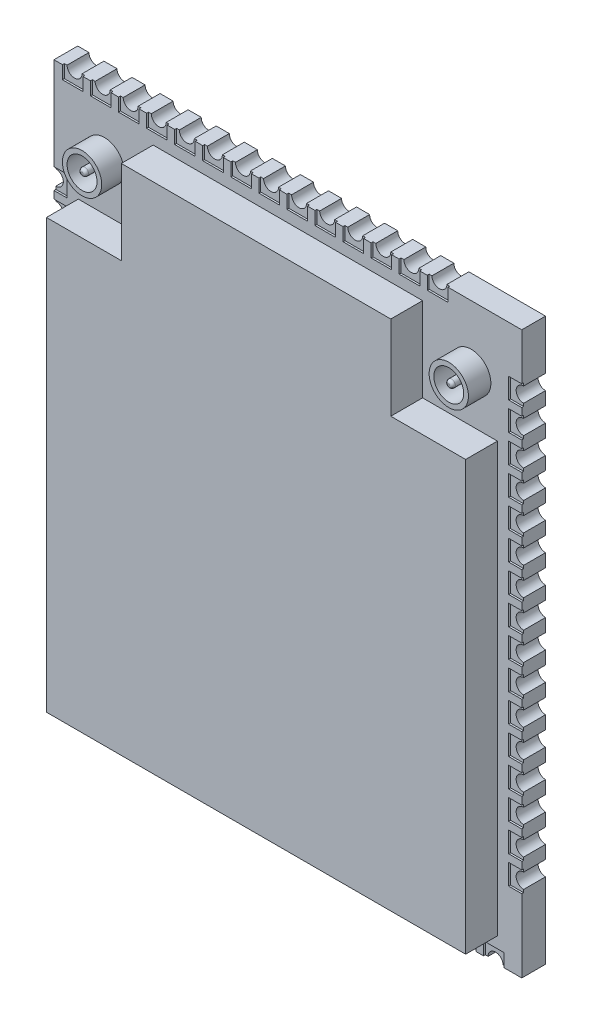
from build123d import *

# Parameters (mm, degrees)
SKETCH1_W            = 25
SKETCH1_H            = 30
BOSS_EXTRUDE1_DEPTH  = 1.27
BOSS_EXTRUDE2_DEPTH  = 1.7
SKETCH3_R            = 1.05
SKETCH3_R_2          = 0.8
SKETCH3_R_3          = 0.2
BOSS_EXTRUDE3_DEPTH  = 1.2
FILLET1_R            = 0.15
FILLET1_OF_MIRROR1_R = 0.15
CUT_EXTRUDE1_DEPTH   = 1.27
SKETCH5_W            = 0.7
SKETCH5_H            = 1.1
CUT_EXTRUDE2_DEPTH   = 0.1
LPATTERN1_COUNT      = 14
LPATTERN1_PITCH      = 1.5
CUT_EXTRUDE3_DEPTH   = 1.27
SKETCH7_W            = 1.1
SKETCH7_H            = 0.7
CUT_EXTRUDE4_DEPTH   = 0.1
CUT_EXTRUDE5_DEPTH   = 1.27
SKETCH10_W           = 0.7
SKETCH10_H           = 1.1
CUT_EXTRUDE6_DEPTH   = 0.1
CUT_EXTRUDE7_DEPTH   = 1.27
SKETCH12_W           = 1.1
SKETCH12_H           = 0.7
CUT_EXTRUDE8_DEPTH   = 0.1
LPATTERN2_COUNT      = 16
LPATTERN2_PITCH      = 1.5
LPATTERN3_COUNT      = 16
LPATTERN3_PITCH      = 1.5
LPATTERN4_COUNT      = 14
LPATTERN4_PITCH      = 1.5


with BuildPart() as part:
    # Sketch1 → Boss-Extrude1 (new body)
    with BuildSketch(Plane.XY):
        with Locations((12.5, 15)):
            Rectangle(SKETCH1_W, SKETCH1_H)
    extrude(amount=BOSS_EXTRUDE1_DEPTH)

    # Sketch2 → Boss-Extrude2 (add)
    with BuildSketch(Plane.XY.offset(1.27)):
        Polygon((5.3, 28.7), (19.7, 28.7), (19.7, 24.2), (23.7, 24.2), (23.7, 1.3), (1.3, 1.3), (1.3, 24.2), (5.3, 24.2), align=None)
    extrude(amount=BOSS_EXTRUDE2_DEPTH)

    # Sketch3 → Boss-Extrude3 (add)
    with BuildSketch(Plane.XY.offset(1.27)):
        with Locations((22.3, 26.7)):
            Circle(SKETCH3_R)
        with Locations((22.3, 26.7)):
            Circle(SKETCH3_R_2, mode=Mode.SUBTRACT)
        with Locations((22.3, 26.7)):
            Circle(SKETCH3_R_3)
    boss_extrude3 = extrude(amount=BOSS_EXTRUDE3_DEPTH)

    # Fillet1
    fillet1_edges = [part.edges().sort_by_distance(p)[0] for p in [
        (22.1, 26.7, 2.47),
    ]]
    fillet(fillet1_edges, radius=FILLET1_R)

    # Mirror1: Boss-Extrude3 across plane
    add(boss_extrude3.mirror(Plane(origin=(12.5, 0, 0), x_dir=(0, 0, 1), z_dir=(1, 0, 0))))

    # Fillet1 of Mirror1
    fillet1_of_mirror1_edges = [part.edges().sort_by_distance(p)[0] for p in [
        (2.9, 26.7, 2.47),
    ]]
    fillet(fillet1_of_mirror1_edges, radius=FILLET1_OF_MIRROR1_R)

    # Sketch4 → Cut-Extrude1 (cut)
    with BuildSketch(Plane.XY.offset(1.27)):
        with BuildLine():
            Line((0, 5.4), (0, 4.6))
            ThreePointArc((0, 4.6), (0.4, 5), (0, 5.4))
        make_face()
    cut_extrude1 = extrude(amount=-CUT_EXTRUDE1_DEPTH, mode=Mode.SUBTRACT)

    # Sketch5 → Cut-Extrude2 (cut)
    with BuildSketch(Plane.XY.offset(1.27)):
        with Locations((0.35, 5)):
            Rectangle(SKETCH5_W, SKETCH5_H)
    cut_extrude2 = extrude(amount=-CUT_EXTRUDE2_DEPTH, mode=Mode.SUBTRACT)

    # LPattern1: Cut-Extrude1, Cut-Extrude2 ×14
    with Locations(*[(0, i * LPATTERN1_PITCH, 0) for i in range(1, LPATTERN1_COUNT)]):
        add(cut_extrude1, mode=Mode.SUBTRACT)
        add(cut_extrude2, mode=Mode.SUBTRACT)

    # Sketch6 → Cut-Extrude3 (cut)
    with BuildSketch(Plane.XY.offset(1.27)):
        with BuildLine():
            Line((0.6, 0), (1.4, 0))
            ThreePointArc((1.4, 0), (1, 0.4), (0.6, 0))
        make_face()
    cut_extrude3 = extrude(amount=-CUT_EXTRUDE3_DEPTH, mode=Mode.SUBTRACT)

    # Sketch7 → Cut-Extrude4 (cut)
    with BuildSketch(Plane.XY.offset(1.27)):
        with Locations((1, 0.35)):
            Rectangle(SKETCH7_W, SKETCH7_H)
    cut_extrude4 = extrude(amount=-CUT_EXTRUDE4_DEPTH, mode=Mode.SUBTRACT)

    # Sketch9 → Cut-Extrude5 (cut)
    with BuildSketch(Plane.XY.offset(1.27)):
        with BuildLine():
            Line((25, 4.85), (25, 4.05))
            ThreePointArc((25, 4.05), (24.6, 4.45), (25, 4.85))
        make_face()
    cut_extrude5 = extrude(amount=-CUT_EXTRUDE5_DEPTH, mode=Mode.SUBTRACT)

    # Sketch10 → Cut-Extrude6 (cut)
    with BuildSketch(Plane.XY.offset(1.27)):
        with Locations((24.65, 4.45)):
            Rectangle(SKETCH10_W, SKETCH10_H)
    cut_extrude6 = extrude(amount=-CUT_EXTRUDE6_DEPTH, mode=Mode.SUBTRACT)

    # Sketch11 → Cut-Extrude7 (cut)
    with BuildSketch(Plane.XY.offset(1.27)):
        with BuildLine():
            Line((0.6, 30), (1.4, 30))
            ThreePointArc((1.4, 30), (1, 29.6), (0.6, 30))
        make_face()
    cut_extrude7 = extrude(amount=-CUT_EXTRUDE7_DEPTH, mode=Mode.SUBTRACT)

    # Sketch12 → Cut-Extrude8 (cut)
    with BuildSketch(Plane.XY.offset(1.27)):
        with Locations((1, 29.65)):
            Rectangle(SKETCH12_W, SKETCH12_H)
    cut_extrude8 = extrude(amount=-CUT_EXTRUDE8_DEPTH, mode=Mode.SUBTRACT)

    # LPattern2: Cut-Extrude3, Cut-Extrude4 ×16
    with Locations(*[(i * LPATTERN2_PITCH, 0, 0) for i in range(1, LPATTERN2_COUNT)]):
        add(cut_extrude3, mode=Mode.SUBTRACT)
        add(cut_extrude4, mode=Mode.SUBTRACT)

    # LPattern3: Cut-Extrude5, Cut-Extrude6 ×16
    with Locations(*[(0, i * LPATTERN3_PITCH, 0) for i in range(1, LPATTERN3_COUNT)]):
        add(cut_extrude5, mode=Mode.SUBTRACT)
        add(cut_extrude6, mode=Mode.SUBTRACT)

    # LPattern4: Cut-Extrude7, Cut-Extrude8 ×14
    with Locations(*[(i * LPATTERN4_PITCH, 0, 0) for i in range(1, LPATTERN4_COUNT)]):
        add(cut_extrude7, mode=Mode.SUBTRACT)
        add(cut_extrude8, mode=Mode.SUBTRACT)


solid = part.part
